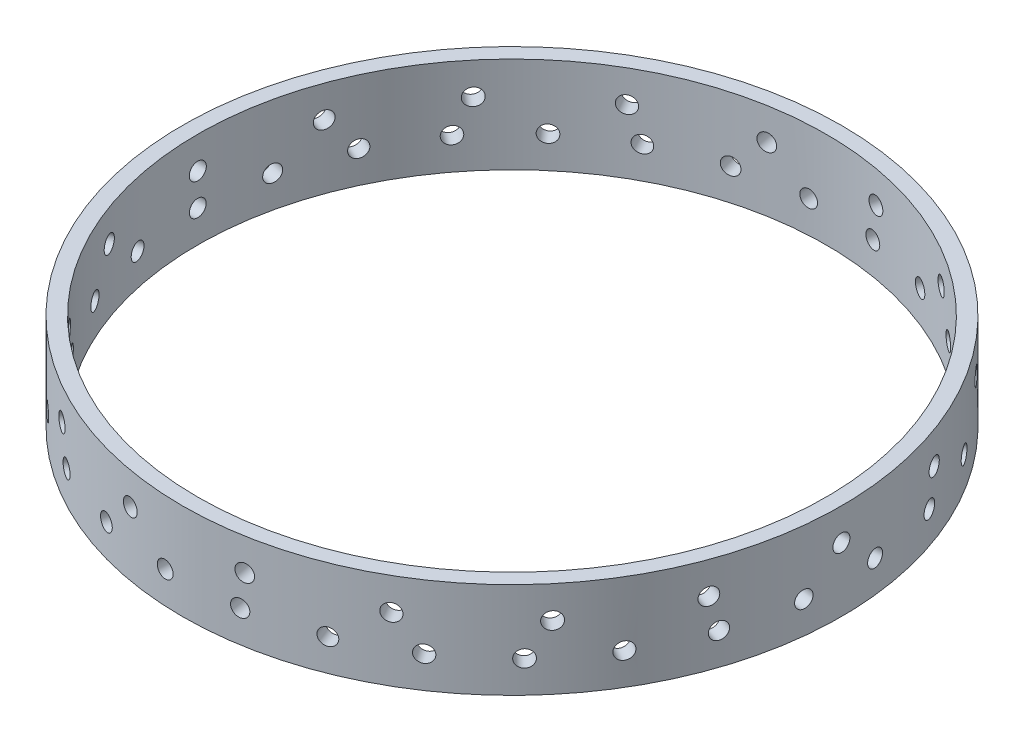
from build123d import *

# Parameters (mm, degrees)
SKETCH1_R           = 68.58
SKETCH1_R_2         = 65.405
BOSS_EXTRUDE1_DEPTH = 19.9644
SKETCH2_R           = 1.75006
CUT_EXTRUDE1_DEPTH  = 81.4324
CIRPATTERN1_COUNT   = 29
SKETCH4_R           = 1.77165
CUT_EXTRUDE2_DEPTH  = 81.4324
CIRPATTERN2_COUNT   = 18


with BuildPart() as part:
    # Sketch1 → Boss-Extrude1 (new body)
    with BuildSketch(Plane(origin=(0, 0, 0), x_dir=(1, 0, 0), z_dir=(0, 1, 0))):
        Circle(SKETCH1_R)
        Circle(SKETCH1_R_2, mode=Mode.SUBTRACT)
    extrude(amount=BOSS_EXTRUDE1_DEPTH)

    # Sketch2 → Cut-Extrude1 (cut)
    with BuildSketch(Plane(origin=(0, 0, 0), x_dir=(0, 0, -1), z_dir=(1, 0, 0))):
        with Locations((0, 6.6548)):
            Circle(SKETCH2_R)
    cut_extrude1 = extrude(amount=-CUT_EXTRUDE1_DEPTH, mode=Mode.SUBTRACT)

    # CirPattern1: Cut-Extrude1 ×29 about axis
    cirpattern1_axis = Axis((0, 0, 0), (0, 1, 0))
    for i in range(1, CIRPATTERN1_COUNT):
        add(cut_extrude1.rotate(cirpattern1_axis, i * 360 / CIRPATTERN1_COUNT), mode=Mode.SUBTRACT)

    # Sketch4 → Cut-Extrude2 (cut)
    with BuildSketch(Plane(origin=(0, 0, 0), x_dir=(0, 0, -1), z_dir=(1, 0, 0))):
        with Locations((0, 13.318066667)):
            Circle(SKETCH4_R)
    cut_extrude2 = extrude(amount=-CUT_EXTRUDE2_DEPTH, mode=Mode.SUBTRACT)

    # CirPattern2: Cut-Extrude2 ×18 about axis
    cirpattern2_axis = Axis((0, 0, 0), (0, 1, 0))
    for i in range(1, CIRPATTERN2_COUNT):
        add(cut_extrude2.rotate(cirpattern2_axis, i * 360 / CIRPATTERN2_COUNT), mode=Mode.SUBTRACT)


solid = part.part
